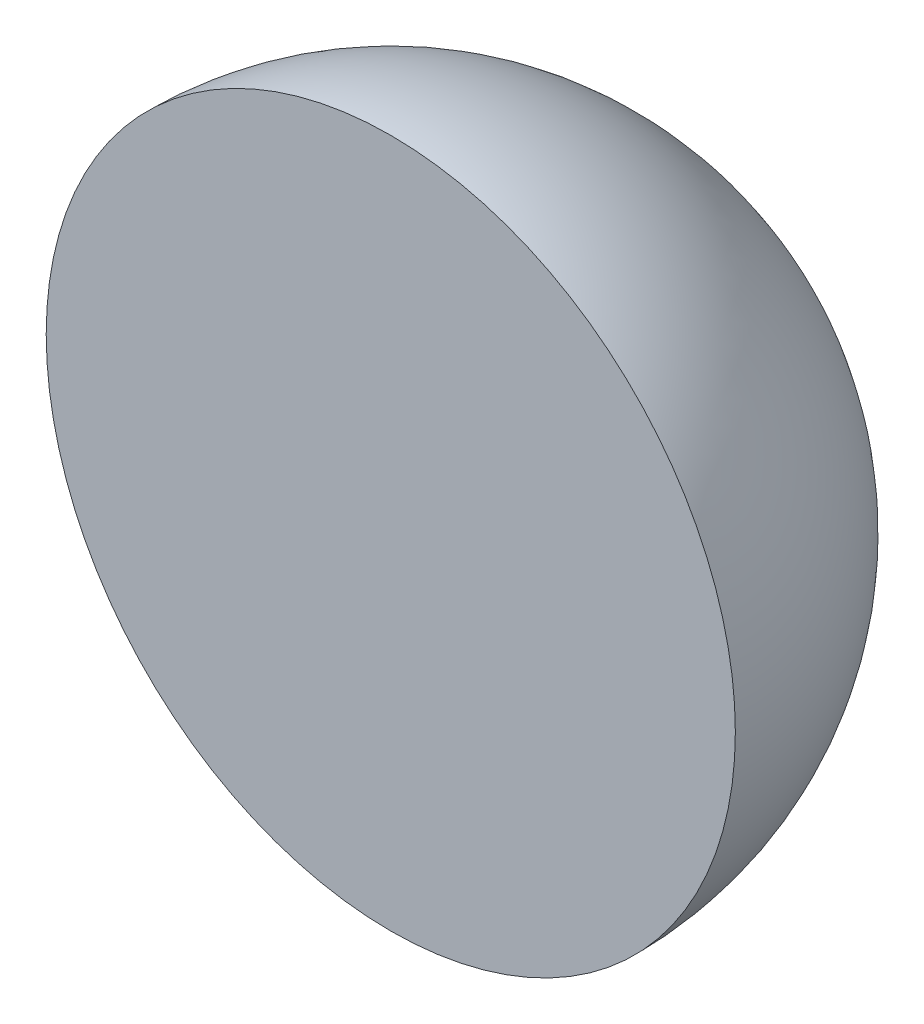
from build123d import *


with BuildPart() as part:
    # 草圖1 → 旋轉1 (revolve)
    with BuildSketch(Plane(origin=(0, 0, 0), x_dir=(1, 0, 0), z_dir=(0, 1, 0))):
        with BuildLine():
            Line((0, 0), (0, 20))
            ThreePointArc((0, 20), (-14.142135624, 14.142135624), (-20, 0))
            Line((-20, 0), (0, 0))
        make_face()
    revolve(axis=Axis((0, 0, 0), (0, 0, -1)))


solid = part.part
